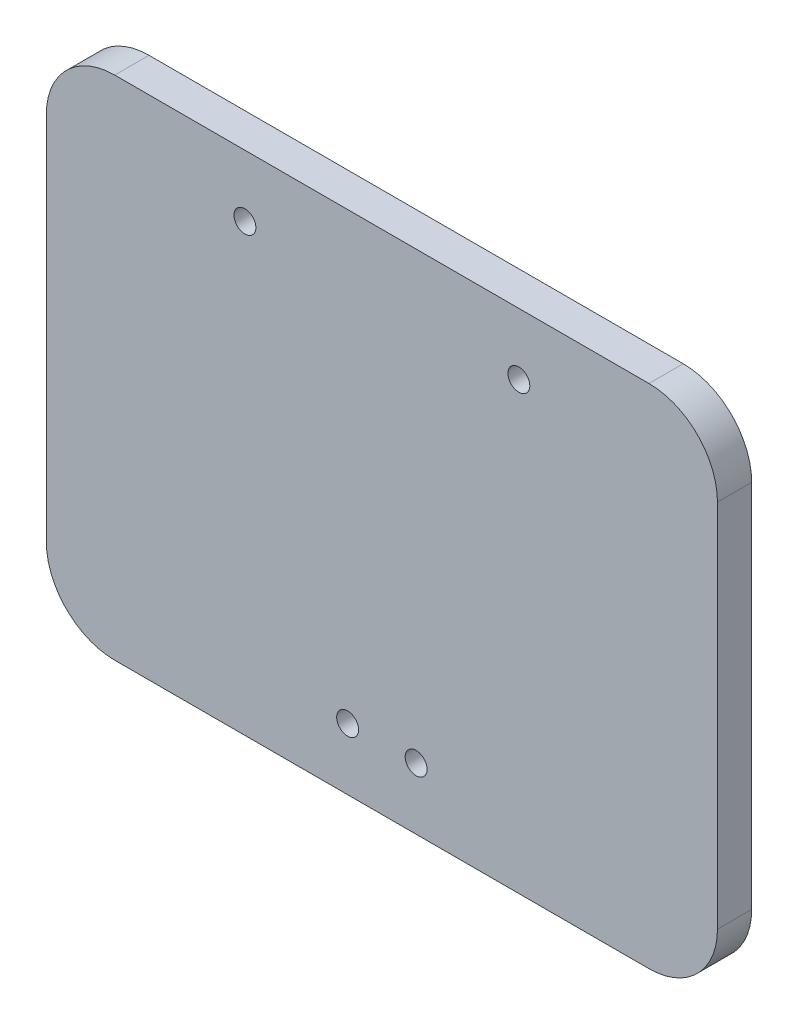
from build123d import *

# Parameters (mm, degrees)
EXTRUDE_1_DEPTH     = 5
SKETCH_3_R          = 1.6
CUT_EXTRUDE_1_DEPTH = 5


with BuildPart() as part:
    # Эскиз2 → Бобышка-Вытянуть1 (new body)
    with BuildSketch(Plane.XY):
        with BuildLine():
            Line((-39, 37), (39, 37))
            ThreePointArc((39, 37), (46.071067812, 34.071067812), (49, 27))
            Line((49, 27), (49, -27))
            ThreePointArc((49, -27), (46.071067812, -34.071067812), (39, -37))
            Line((39, -37), (-39, -37))
            ThreePointArc((-39, -37), (-46.071067812, -34.071067812), (-49, -27))
            Line((-49, -27), (-49, 27))
            ThreePointArc((-49, 27), (-46.071067812, 34.071067812), (-39, 37))
        make_face()
    extrude(amount=EXTRUDE_1_DEPTH)

    # Эскиз3 → Вырез-Вытянуть1 (cut)
    with BuildSketch(Plane.XY.offset(5)):
        with Locations((5, -28)):
            Circle(SKETCH_3_R)
        with Locations((-5, -28)):
            Circle(SKETCH_3_R)
        with Locations((-20, 28)):
            Circle(SKETCH_3_R)
        with Locations((20, 28)):
            Circle(SKETCH_3_R)
    extrude(amount=-CUT_EXTRUDE_1_DEPTH, mode=Mode.SUBTRACT)


solid = part.part
